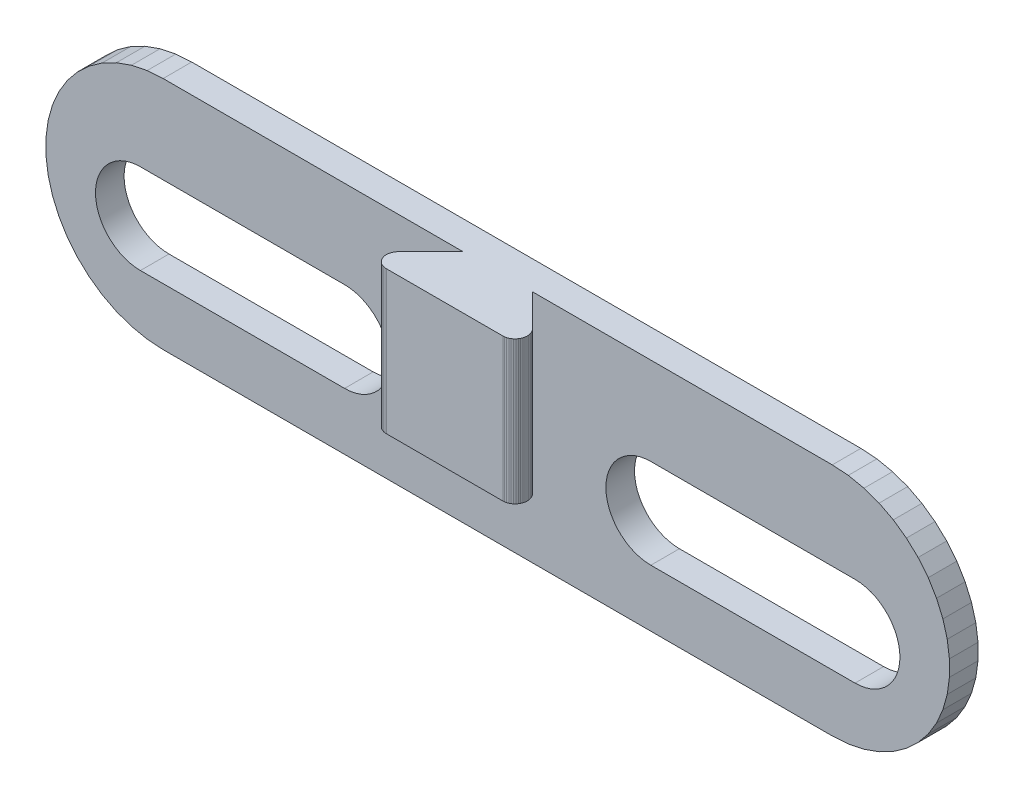
from build123d import *

# Parameters (mm, degrees)
BOSS_EXTRUDE1_DEPTH = 1.39999995
CUT_EXTRUDE1_DEPTH  = 2.39999995
BOSS_EXTRUDE2_DEPTH = 6.99999975


with BuildPart() as part:
    # Sketch1 → Boss-Extrude1 (new body)
    with BuildSketch(Plane.XY.offset(-1.200000057)):
        Polygon((17.170472071, 2.74639437), (16.38751477, 2.799950074), (-16.38751477, 2.799950074), (-17.170472071, 2.74639437), (-17.93884486, 2.586724702), (-18.678320572, 2.323914785), (-19.375121221, 1.962861512), (-20.016269758, 1.510289963), (-20.589821041, 0.974630471), (-21.085090935, 0.365861692), (-21.492853761, -0.304676127), (-21.80551365, -1.024491969), (-22.017247975, -1.780177932), (-22.12410979, -2.557656262), (-22.12410979, -3.342443844), (-22.017247975, -4.119921941), (-21.80551365, -4.875607789), (-21.492853761, -5.595424213), (-21.085090935, -6.265962031), (-20.589821041, -6.874730811), (-20.016269758, -7.410389837), (-19.375121221, -7.862961851), (-18.678320572, -8.224015124), (-17.93884486, -8.48682411), (-17.170472071, -8.646493778), (-16.38751477, -8.700050414), (16.38751477, -8.700050414), (17.170472071, -8.646493778), (17.93884486, -8.48682411), (18.678320572, -8.224015124), (19.375121221, -7.862961851), (20.016269758, -7.410389837), (20.589821041, -6.874730811), (21.085090935, -6.265962031), (21.492853761, -5.595424213), (21.80551365, -4.875607789), (22.017247975, -4.119921941), (22.12410979, -3.342443844), (22.12410979, -2.557656262), (22.017247975, -1.780177932), (21.80551365, -1.024491969), (21.492853761, -0.304676127), (21.085090935, 0.365861692), (20.589821041, 0.974630471), (20.016269758, 1.510289963), (19.375121221, 1.962861512), (18.678320572, 2.323914785), (17.93884486, 2.586724702), align=None)
    extrude(amount=-BOSS_EXTRUDE1_DEPTH)

    # Sketch2 → Cut-Extrude1 (cut, through all)
    with BuildSketch(Plane.XY.offset(-1.200000057)):
        with BuildLine():
            Line((-7.499999832, -5.900050048), (-17.500000075, -5.900050048))
            ThreePointArc((-17.500000075, -5.900050048), (-19.700000075, -3.700050048), (-17.500000075, -1.500050048))
            Line((-17.500000075, -1.500050048), (-7.499999832, -1.500050048))
            ThreePointArc((-7.499999832, -1.500050048), (-5.299999832, -3.700050048), (-7.499999832, -5.900050048))
        make_face()
    cut_extrude1 = extrude(amount=-CUT_EXTRUDE1_DEPTH, mode=Mode.SUBTRACT)

    # Mirror1: Cut-Extrude1 across plane
    add(cut_extrude1.mirror(Plane(origin=(0, 0, 0), x_dir=(0, 0, 1), z_dir=(1, 0, 0))), mode=Mode.SUBTRACT)

    # Sketch4 → Boss-Extrude2 (add)
    with BuildSketch(Plane(origin=(0, 2.799950074, 0), x_dir=(1, 0, 0), z_dir=(0, 1, 0))):
        Polygon((3.330282168, -0.438419171), (3.275736002, -0.375735923), (1.700000023, 1.200000057), (-1.700000023, 1.200000057), (-3.275736002, -0.375735923), (-3.330282168, -0.438419171), (-3.375645261, -0.508037279), (-3.410955193, -0.583254965), (-3.435534658, -0.662629609), (-3.448912408, -0.744638965), (-3.450831631, -0.827709911), (-3.441255772, -0.910249539), (-3.420368303, -0.990674831), (-3.388569923, -1.067443052), (-3.346470417, -1.139081782), (-3.294877242, -1.204217318), (-3.234779928, -1.261600293), (-3.167331219, -1.310130116), (-3.093824489, -1.348876162), (-3.015669761, -1.377095236), (-2.934365766, -1.394246239), (-2.851471771, -1.39999995), (2.851471771, -1.39999995), (2.934365766, -1.394246239), (3.015669761, -1.377095236), (3.093824489, -1.348876162), (3.167331219, -1.310130116), (3.234779928, -1.261600293), (3.294877242, -1.204217318), (3.346470417, -1.139081782), (3.388569923, -1.067443052), (3.420368303, -0.990674831), (3.441255772, -0.910249539), (3.450831631, -0.827709911), (3.448912408, -0.744638965), (3.435534658, -0.662629609), (3.410955193, -0.583254965), (3.375645261, -0.508037279), align=None)
    extrude(amount=-BOSS_EXTRUDE2_DEPTH)


solid = part.part
